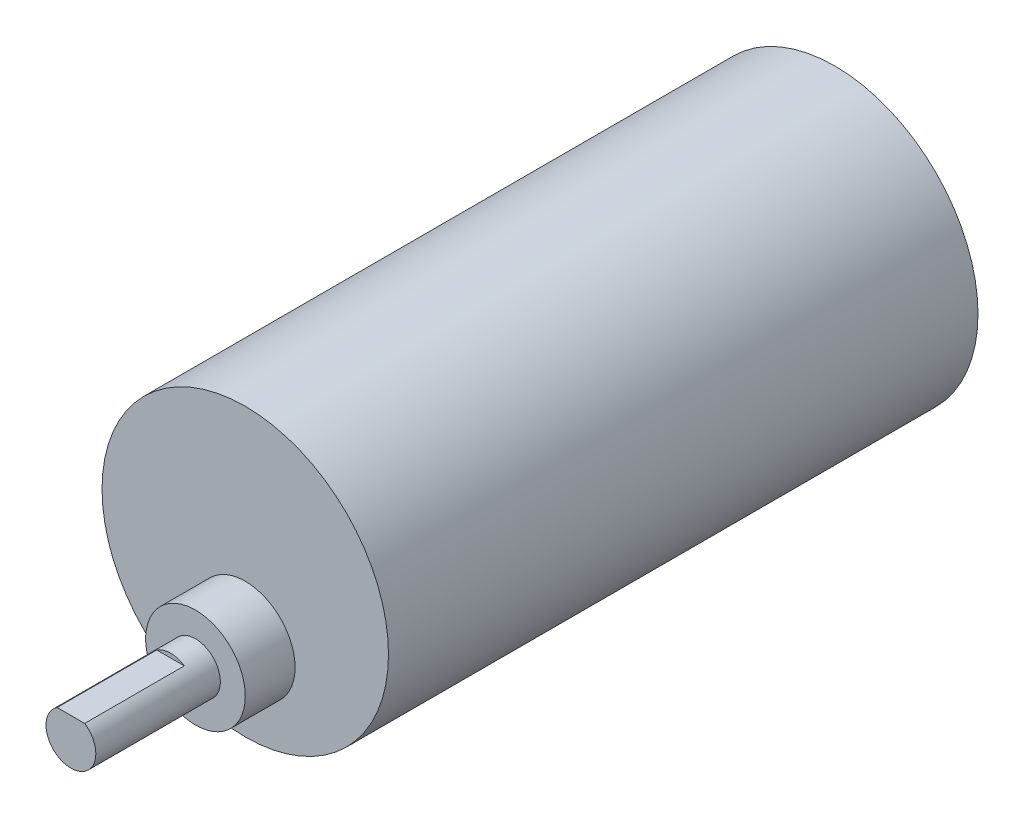
from build123d import *

# Parameters (mm, degrees)
SKETCH_1_R          = 17.25
EXTRUDE_1_DEPTH     = 71
SKETCH_2_R          = 6
EXTRUDE_2_DEPTH     = 6
SKETCH_3_R          = 3
EXTRUDE_3_DEPTH     = 15
CUT_EXTRUDE_1_DEPTH = 12


with BuildPart() as part:
    # 草图1 → 凸台-拉伸1 (new body)
    with BuildSketch(Plane.XY):
        Circle(SKETCH_1_R)
    extrude(amount=EXTRUDE_1_DEPTH)

    # 草图2 → 凸台-拉伸2 (add)
    with BuildSketch(Plane.XY.offset(71)):
        with Locations((0, -7)):
            Circle(SKETCH_2_R)
    extrude(amount=EXTRUDE_2_DEPTH)

    # 草图3 → 凸台-拉伸3 (add)
    with BuildSketch(Plane.XY.offset(77)):
        with Locations((0, -7)):
            Circle(SKETCH_3_R)
    extrude(amount=EXTRUDE_3_DEPTH)

    # 草图4 → 切除-拉伸1 (cut)
    with BuildSketch(Plane.XY.offset(92)):
        Polygon((-3.407266726, -4.5), (4.657639837, -4.5), (3.969934626, -3.172821768), (-3.407266726, -3.172821768), align=None)
    extrude(amount=-CUT_EXTRUDE_1_DEPTH, mode=Mode.SUBTRACT)


solid = part.part
